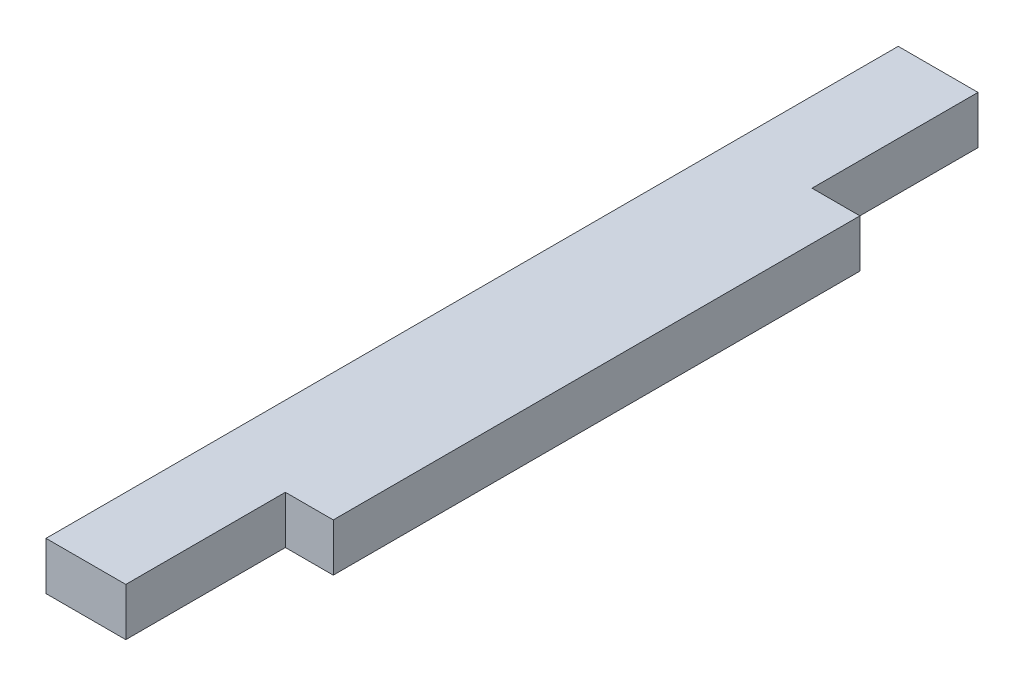
from build123d import *

# Parameters (mm, degrees)
ESQUISSE1_W        = 5
ESQUISSE1_H        = 3
BOSS_EXTRU_1_DEPTH = 53.4
ESQUISSE2_W        = 33
ESQUISSE2_H        = 3
BOSS_EXTRU_2_DEPTH = 3


with BuildPart() as part:
    # Esquisse1 → Boss.-Extru.1 (new body)
    with BuildSketch(Plane.XY):
        with Locations((106.062592566, -77)):
            Rectangle(ESQUISSE1_W, ESQUISSE1_H)
    extrude(amount=BOSS_EXTRU_1_DEPTH)

    # Esquisse2 → Boss.-Extru.2 (add)
    with BuildSketch(Plane(origin=(108.562592566, 0, 0), x_dir=(0, 0, -1), z_dir=(1, 0, 0))):
        with Locations((-26.9, -77)):
            Rectangle(ESQUISSE2_W, ESQUISSE2_H)
    extrude(amount=BOSS_EXTRU_2_DEPTH)


solid = part.part
